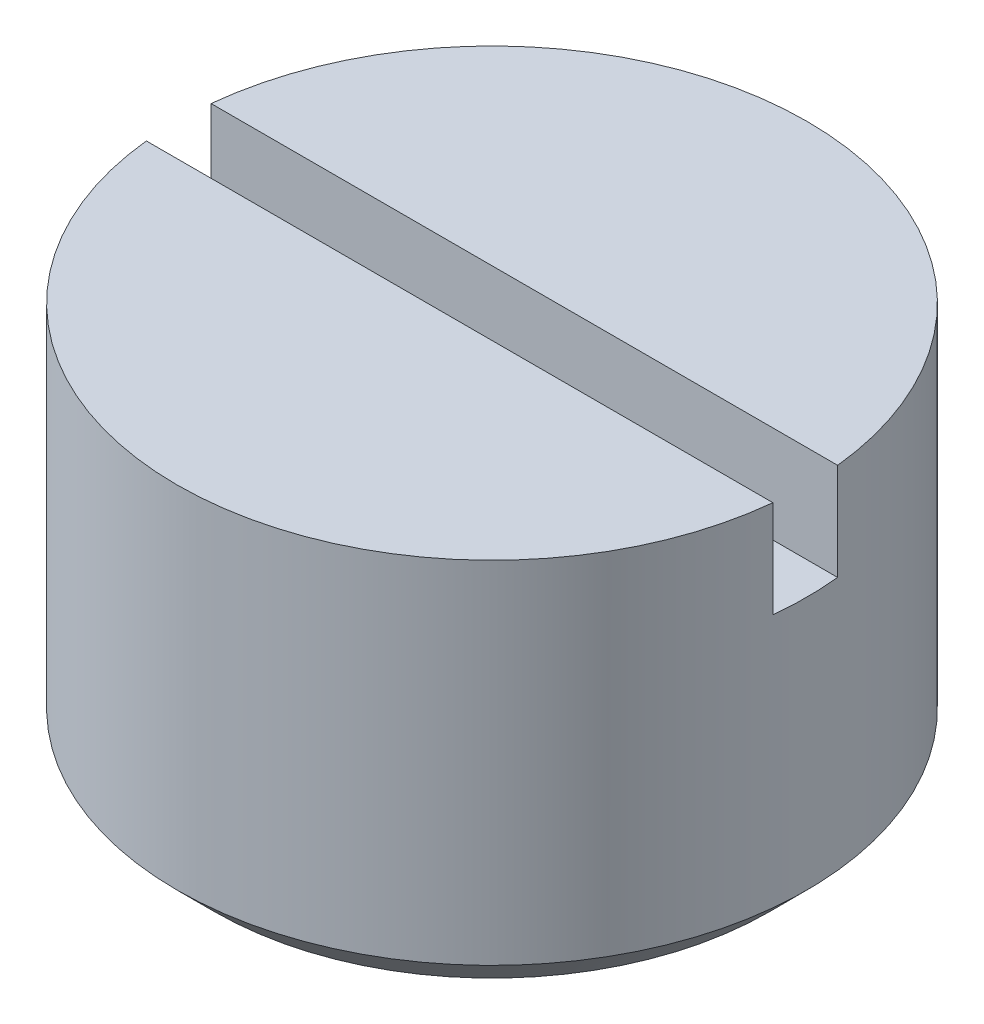
from build123d import *

# Parameters (mm, degrees)
SKETCH2_W          = 9.728
SKETCH2_H          = 1
CUT_EXTRUDE1_DEPTH = 1.5


with BuildPart() as part:
    # Sketch1 → Revolve1 (revolve)
    with BuildSketch(Plane.XY):
        Polygon((0, 0), (4.864, 0), (4.864, -5.419), (4.283, -6), (0, -6), align=None)
    revolve(axis=Axis((0, -6, 0), (0, 1, 0)))

    # Sketch2 → Cut-Extrude1 (cut)
    with BuildSketch(Plane(origin=(0, 0, 0), x_dir=(1, 0, 0), z_dir=(0, 1, 0))):
        Rectangle(SKETCH2_W, SKETCH2_H)
    extrude(amount=-CUT_EXTRUDE1_DEPTH, mode=Mode.SUBTRACT)


solid = part.part
